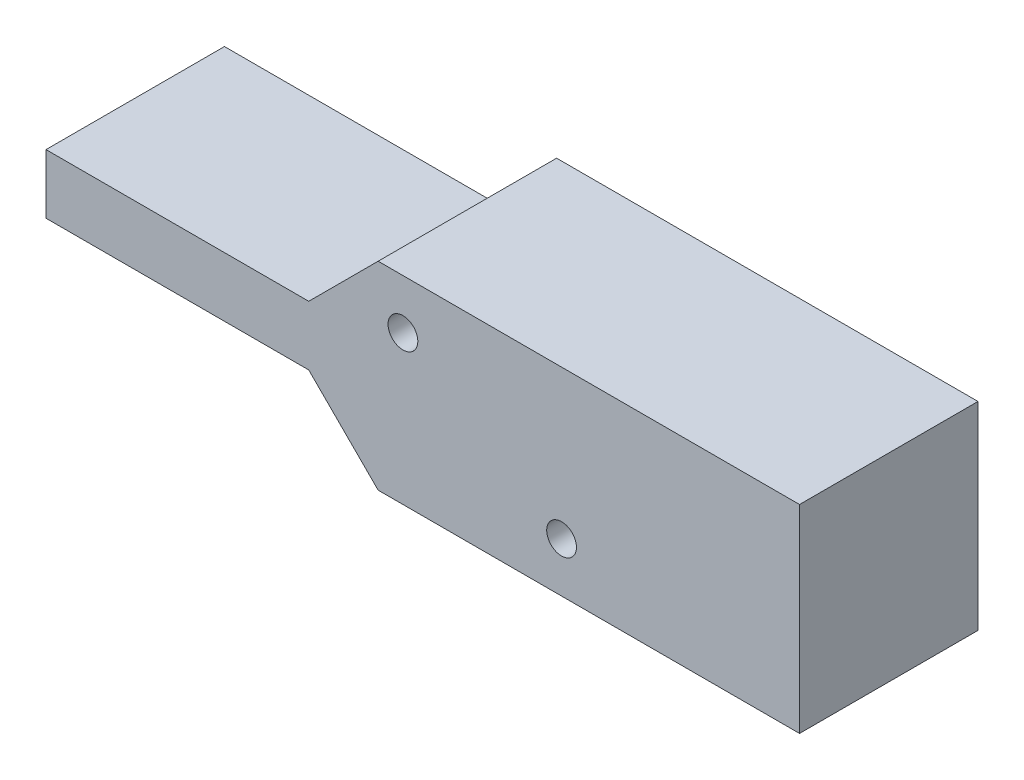
from build123d import *

# Parameters (mm, degrees)
SKIZZE1_R                       = 1.5
AUFSATZ_LINEAR_AUSTRAGEN1_DEPTH = 18


with BuildPart() as part:
    # Skizze1 → Aufsatz-Linear austragen1 (new body)
    with BuildSketch(Plane.XY):
        Polygon((-76, -7), (-76, -13), (-49.5, -13), (-42.5, -20), (0, -20), (0, 0), (-42.5, 0), (-49.5, -7), align=None)
        with Locations((-40, -5)):
            Circle(SKIZZE1_R, mode=Mode.SUBTRACT)
        with Locations((-24, -15)):
            Circle(SKIZZE1_R, mode=Mode.SUBTRACT)
    extrude(amount=AUFSATZ_LINEAR_AUSTRAGEN1_DEPTH)


solid = part.part
